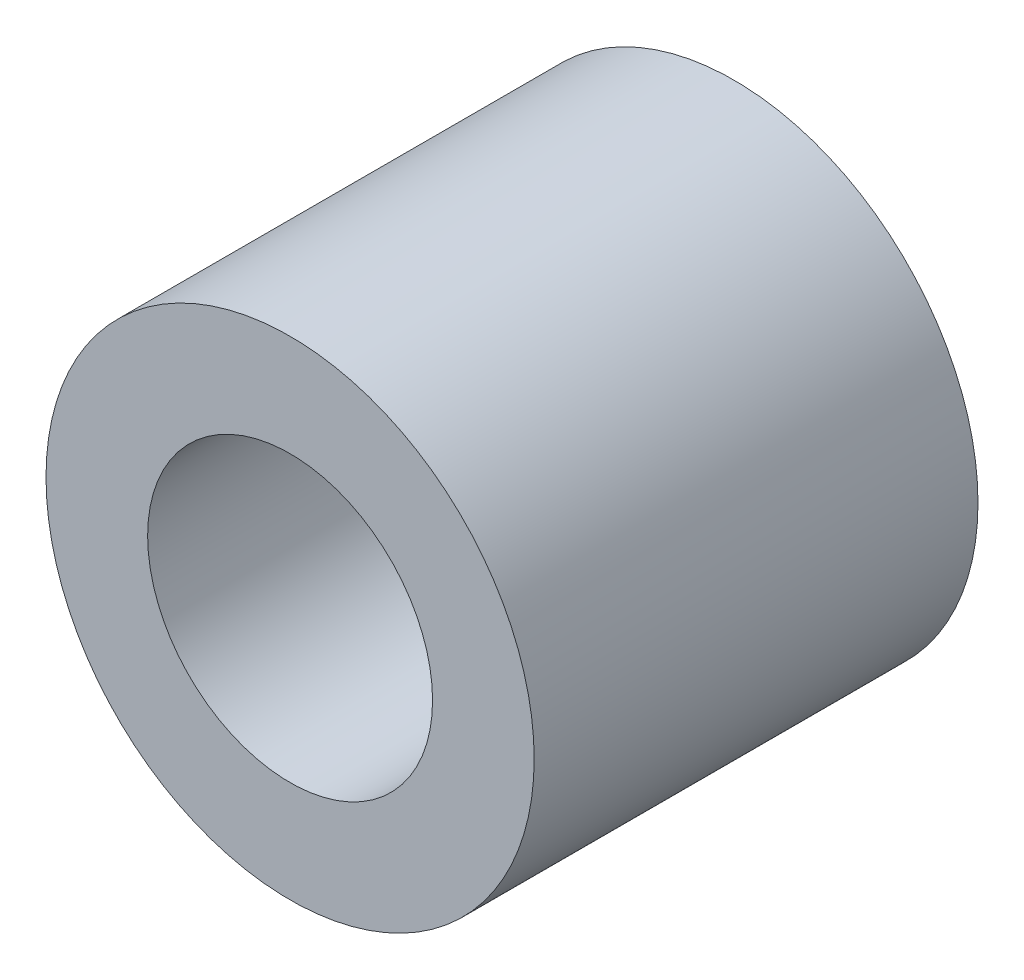
from build123d import *

# Parameters (mm, degrees)
ESQUISSE1_R             = 27.5
BOSS_EXTRU_1_DEPTH      = 20
ESQUISSE2_R             = 27.5
BOSS_EXTRU_2_DEPTH      = 50
ESQUISSE3_R             = 16.05
ENL_V_MAT_EXTRU_1_DEPTH = 51


with BuildPart() as part:
    # Esquisse1 → Boss.-Extru.1 (new body)
    with BuildSketch(Plane.XY):
        Circle(ESQUISSE1_R)
    extrude(amount=BOSS_EXTRU_1_DEPTH)

    # Esquisse2 → Boss.-Extru.2 (add)
    with BuildSketch(Plane.XY):
        Circle(ESQUISSE2_R)
    extrude(amount=BOSS_EXTRU_2_DEPTH)

    # Esquisse3 → Enlèv. mat.-Extru.1 (cut, through all)
    with BuildSketch(Plane(origin=(0, 0, 0), x_dir=(-1, 0, 0), z_dir=(0, 0, -1))):
        Circle(ESQUISSE3_R)
    extrude(amount=-ENL_V_MAT_EXTRU_1_DEPTH, mode=Mode.SUBTRACT)


solid = part.part
